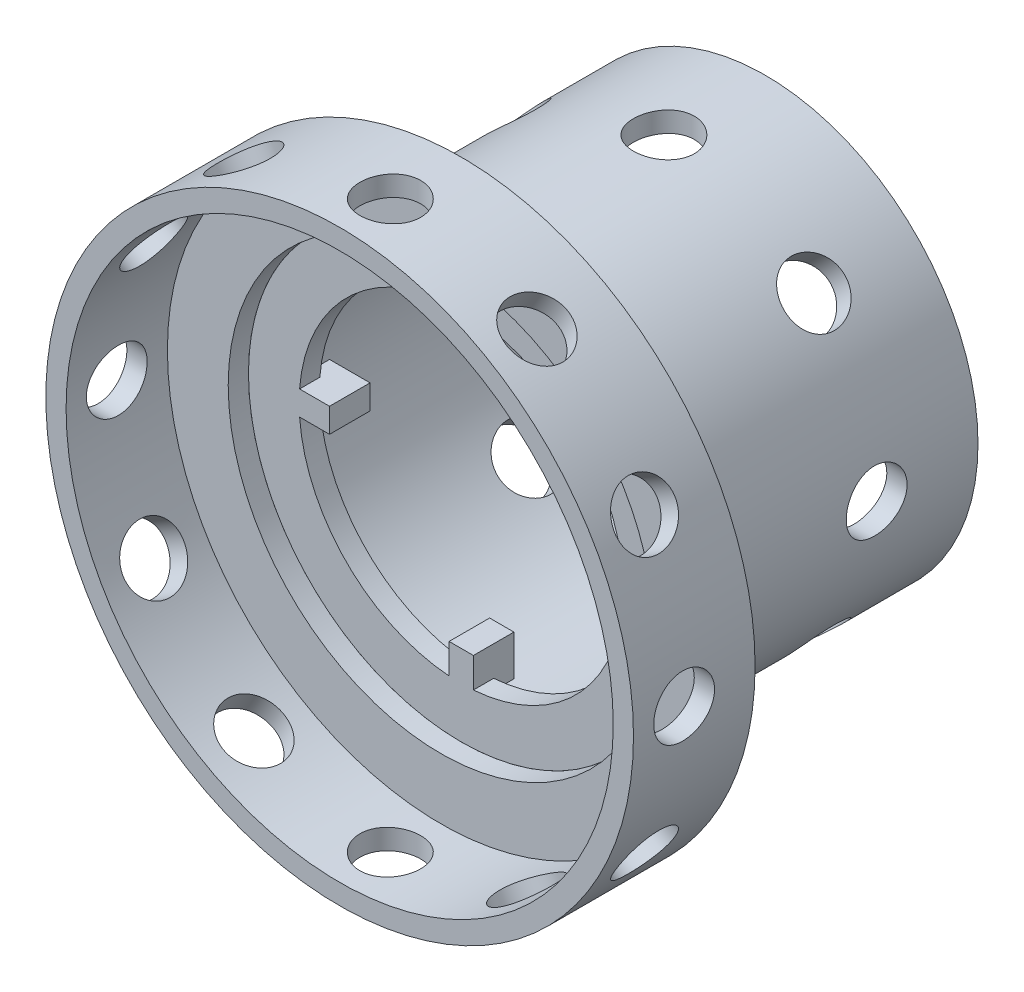
from build123d import *

# Parameters (mm, degrees)
EXTRUDE_START            = 10
SKETCH_1_R               = 10.5
SKETCH_1_R_2             = 9.5
EXTRUDE_1_DEPTH          = 15
EXTRUDE_START_2          = 25
SKETCH_6_R               = 10
SKETCH_6_R_2             = 8
EXTRUDE_3_DEPTH          = 1
SKETCH_5_W               = 2
SKETCH_5_H               = 1.2
EXTRUDE_4_DEPTH          = 2
PATTERN_CIRCULAR_1_COUNT = 4
SKETCH_7_R               = 1.5
CUT_EXTRUDE_2_DEPTH      = 20
PATTERN_CIRCULAR_2_COUNT = 8
SKETCH_8_R               = 14.5
SKETCH_8_R_2             = 10.5
EXTRUDE_5_DEPTH          = 6
SKETCH_9_R               = 13.5
CUT_EXTRUDE_3_DEPTH      = 5
SKETCH_10_R              = 1.5
CUT_EXTRUDE_4_DEPTH      = 15.5
PATTERN_CIRCULAR_4_COUNT = 12


with BuildPart() as part:
    # ｽｹｯﾁ1 → ﾎﾞｽ - 押し出し1 (new body)
    with BuildSketch(Plane.XY.offset(EXTRUDE_START)):
        Circle(SKETCH_1_R)
        Circle(SKETCH_1_R_2, mode=Mode.SUBTRACT)
    extrude(amount=EXTRUDE_1_DEPTH)

    # ｽｹｯﾁ6 → ﾎﾞｽ - 押し出し3 (add)
    with BuildSketch(Plane.XY.offset(EXTRUDE_START_2)):
        Circle(SKETCH_6_R)
        Circle(SKETCH_6_R_2, mode=Mode.SUBTRACT)
    extrude(amount=-EXTRUDE_3_DEPTH)

    # ｽｹｯﾁ5 → ﾎﾞｽ - 押し出し4 (add)
    with BuildSketch(Plane.XY.offset(25)):
        with Locations((7.5, 0)):
            Rectangle(SKETCH_5_W, SKETCH_5_H)
    extrude_4 = extrude(amount=-EXTRUDE_4_DEPTH)

    # 円形ﾊﾟﾀｰﾝ1: ﾎﾞｽ - 押し出し4 ×4 about axis
    pattern_circular_1_axis = Axis((0, 0, 0), (0, 0, 1))
    for i in range(1, PATTERN_CIRCULAR_1_COUNT):
        add(extrude_4.rotate(pattern_circular_1_axis, i * 360 / PATTERN_CIRCULAR_1_COUNT))

    # ｽｹｯﾁ7 → ｶｯﾄ - 押し出し2 (cut, symmetric)
    with BuildSketch(Plane(origin=(0, 0, 0), x_dir=(0, 0, -1), z_dir=(1, 0, 0))):
        with Locations((-15, 0)):
            Circle(SKETCH_7_R)
    cut_extrude_2 = extrude(amount=CUT_EXTRUDE_2_DEPTH, both=True, mode=Mode.SUBTRACT)

    # 円形ﾊﾟﾀｰﾝ2: ｶｯﾄ - 押し出し2 ×8 about axis
    pattern_circular_2_axis = Axis((0, 0, 24), (0, 0, 1))
    for i in range(1, PATTERN_CIRCULAR_2_COUNT):
        add(cut_extrude_2.rotate(pattern_circular_2_axis, i * 360 / PATTERN_CIRCULAR_2_COUNT), mode=Mode.SUBTRACT)


with BuildPart() as body_2:
    # ｽｹｯﾁ8 → ﾎﾞｽ - 押し出し5 (new body)
    with BuildSketch(Plane.XY.offset(25)):
        Circle(SKETCH_8_R)
        Circle(SKETCH_8_R_2, mode=Mode.SUBTRACT)
    extrude(amount=EXTRUDE_5_DEPTH)

    # ｽｹｯﾁ9 → ｶｯﾄ - 押し出し3 (cut)
    with BuildSketch(Plane(origin=(0, 0, 31), x_dir=(-1, 0, 0), z_dir=(0, 0, -1))):
        Circle(SKETCH_9_R)
    extrude(amount=CUT_EXTRUDE_3_DEPTH, mode=Mode.SUBTRACT)

    # ｽｹｯﾁ10 → ｶｯﾄ - 押し出し4 (cut, through all)
    with BuildSketch(Plane(origin=(0, 0, 0), x_dir=(0, 0, -1), z_dir=(1, 0, 0))):
        with Locations((-28.5, 0)):
            Circle(SKETCH_10_R)
    cut_extrude_4 = extrude(amount=CUT_EXTRUDE_4_DEPTH, mode=Mode.SUBTRACT)

    # 円形ﾊﾟﾀｰﾝ4: ｶｯﾄ - 押し出し4 ×12 about axis
    pattern_circular_4_axis = Axis((0, 0, 31), (0, 0, -1))
    for i in range(1, PATTERN_CIRCULAR_4_COUNT):
        add(cut_extrude_4.rotate(pattern_circular_4_axis, i * 360 / PATTERN_CIRCULAR_4_COUNT), mode=Mode.SUBTRACT)


solid = Compound([part.part, body_2.part])
